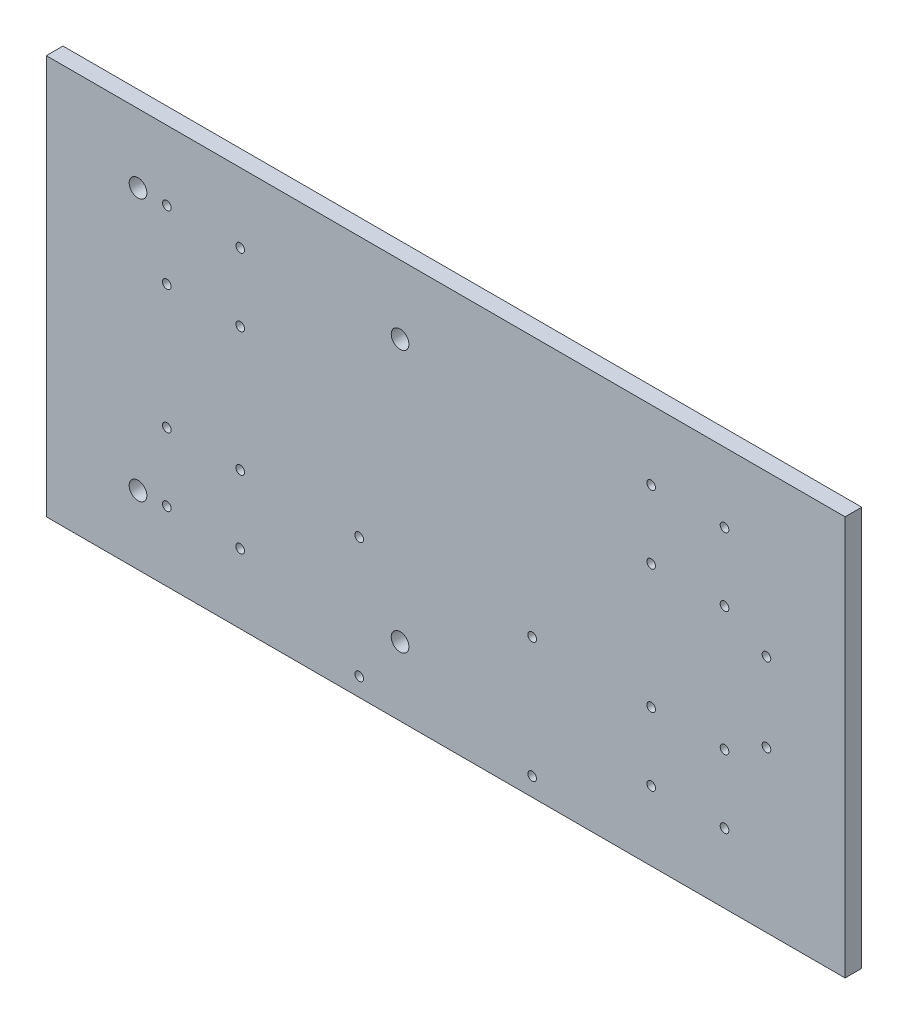
from build123d import *

# Parameters (mm, degrees)
SKETCH1_W                 = 304.8
SKETCH1_H                 = 152.4
BOSS_EXTRUDE1_DEPTH       = 6.35
M4X0_7_TAPPED_HOLE1_D     = 3.3
M4X0_7_TAPPED_HOLE1_DEPTH = 10.1
M4X0_7_TAPPED_HOLE1_TIP   = 1.65
SKETCH5_R                 = 3.375
CUT_EXTRUDE1_DEPTH        = 7.35
SKETCH6_R                 = 1.65
CUT_EXTRUDE2_DEPTH        = 7.35
SKETCH7_R                 = 1.65
CUT_EXTRUDE3_DEPTH        = 7.35


with BuildPart() as part:
    # Sketch1 → Boss-Extrude1 (new body)
    with BuildSketch(Plane.XY):
        Rectangle(SKETCH1_W, SKETCH1_H)
    extrude(amount=BOSS_EXTRUDE1_DEPTH)

    # M4x0.7 Tapped Hole1
    with Locations(Plane(origin=(78.4, 49.7, 0), x_dir=(-1, 0, 0), z_dir=(0, 0, -1))):
        with Locations((0, 0), (0, -26), (-28, -26), (-28, 0), (0, -73.4), (0, -99.4), (-28, -73.4), (-28, -99.4), (184.8, 0), (156.8, 0), (156.8, -26), (184.8, -26), (184.8, -73.4), (184.8, -99.4), (156.8, -73.4), (156.8, -99.4)):
            Hole(M4X0_7_TAPPED_HOLE1_D / 2, depth=M4X0_7_TAPPED_HOLE1_DEPTH)
            with Locations((0, 0, -(M4X0_7_TAPPED_HOLE1_DEPTH + M4X0_7_TAPPED_HOLE1_TIP / 2))):  # 90° drill point
                Cone(0, M4X0_7_TAPPED_HOLE1_D / 2, M4X0_7_TAPPED_HOLE1_TIP, mode=Mode.SUBTRACT)

    # Sketch5 → Cut-Extrude1 (cut, through all)
    with BuildSketch(Plane.XY.offset(6.35)):
        with Locations((-117.4, -50.000126651)):
            Circle(SKETCH5_R)
        with Locations((-117.4, 49.999873349)):
            Circle(SKETCH5_R)
        with Locations((-17.4, -50.000126651)):
            Circle(SKETCH5_R)
        with Locations((-17.4, 49.999873349)):
            Circle(SKETCH5_R)
    extrude(amount=-CUT_EXTRUDE1_DEPTH, mode=Mode.SUBTRACT)

    # Sketch6 → Cut-Extrude2 (cut, through all)
    with BuildSketch(Plane(origin=(0, 0, 0), x_dir=(-1, 0, 0), z_dir=(0, 0, -1))):
        with Locations((33, -69.2)):
            Circle(SKETCH6_R)
        with Locations((33, -23.2)):
            Circle(SKETCH6_R)
        with Locations((-33, -23.2)):
            Circle(SKETCH6_R)
        with Locations((-33, -69.2)):
            Circle(SKETCH6_R)
    extrude(amount=-CUT_EXTRUDE2_DEPTH, mode=Mode.SUBTRACT)

    # Sketch7 → Cut-Extrude3 (cut, through all)
    with BuildSketch(Plane.XY.offset(6.35)):
        with Locations((122.4, 15)):
            Circle(SKETCH7_R)
        with Locations((122.4, -15)):
            Circle(SKETCH7_R)
    extrude(amount=-CUT_EXTRUDE3_DEPTH, mode=Mode.SUBTRACT)


solid = part.part
